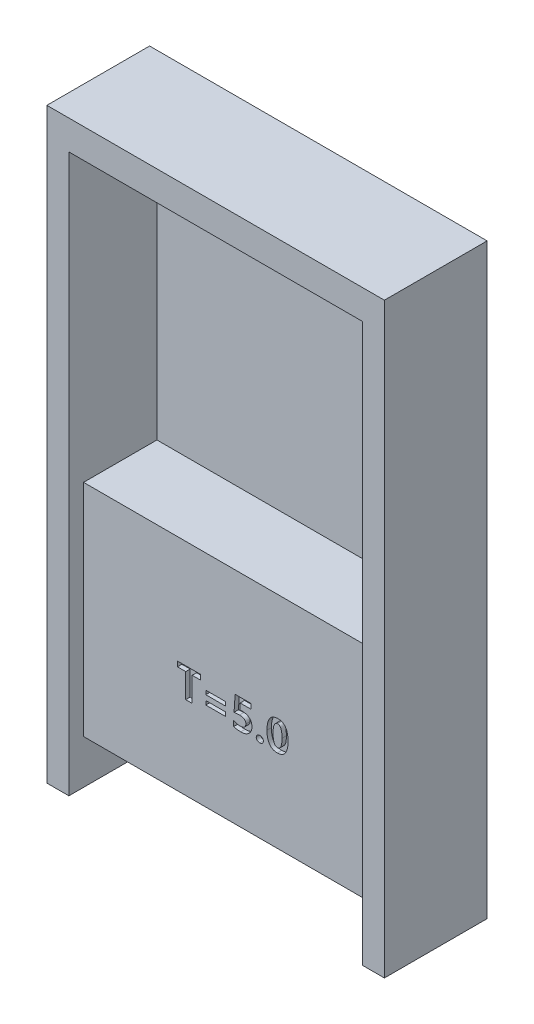
from build123d import *

# Parameters (mm, degrees)
EXTRUDE_1_DEPTH     = 7
SKETCH_2_W          = 20
SKETCH_2_H          = 35
EXTRUDE_2_DEPTH     = 6
SKETCH_3_W          = 20
SKETCH_3_H          = 20
CUT_EXTRUDE_1_DEPTH = 5
SKETCH_4_W          = 14
SKETCH_4_H          = 10
CUT_EXTRUDE_2_DEPTH = 5
SKETCH_5_W          = 1.341463414
SKETCH_5_H          = 0.268292683
CUT_EXTRUDE_3_DEPTH = 0.3


with BuildPart() as part:
    # 草图1 → 凸台-拉伸1 (new body)
    with BuildSketch(Plane.XY):
        Polygon((-10, 0), (-10, -18), (-11.5, -18), (-11.5, 22), (11.5, 22), (11.5, -18), (10, -18), (10, 0), (10, 20), (-10, 20), align=None)
    extrude(amount=EXTRUDE_1_DEPTH)

    # 草图2 → 凸台-拉伸2 (add)
    with BuildSketch(Plane.XY):
        with Locations((0, 2.5)):
            Rectangle(SKETCH_2_W, SKETCH_2_H)
    extrude(amount=EXTRUDE_2_DEPTH)

    # 草图3 → 切除-拉伸1 (cut)
    with BuildSketch(Plane.XY.offset(6)):
        with Locations((0, 10)):
            Rectangle(SKETCH_3_W, SKETCH_3_H)
    extrude(amount=-CUT_EXTRUDE_1_DEPTH, mode=Mode.SUBTRACT)

    # 草图4 → 切除-拉伸2 (cut)
    with BuildSketch(Plane(origin=(0, 0, 0), x_dir=(-1, 0, 0), z_dir=(0, 0, -1))):
        with Locations((0, -7)):
            Rectangle(SKETCH_4_W, SKETCH_4_H)
    extrude(amount=-CUT_EXTRUDE_2_DEPTH, mode=Mode.SUBTRACT)

    # 草图5 → 切除-拉伸3 (cut)
    with BuildSketch(Plane.XY.offset(6)):
        Polygon((-2.038957757, -7.685646489), (-2.599933366, -7.685646489), (-2.599933366, -9.344183074), (-3.038957757, -9.344183074), (-3.038957757, -7.685646489), (-3.599933366, -7.685646489), (-3.599933366, -7.344183074), (-2.038957757, -7.344183074), align=None)
        with Locations((-1.002372391, -8.234426976)):
            Rectangle(SKETCH_5_W, SKETCH_5_H)
        with Locations((-1.002372391, -8.844183075)):
            Rectangle(SKETCH_5_W, SKETCH_5_H)
        with BuildLine():
            Line((0.229334926, -9.295402586), (0.229334926, -8.925356855))
            add(Edge.make_bspline(
                [(0.229334926, -8.925356855), (0.246853092, -8.935526495), (0.281528867, -8.955656466), (0.335668265, -8.981092143), (0.390451653, -9.002970359), (0.446303794, -9.020435919), (0.502817727, -9.034248611), (0.560116273, -9.044076789), (0.61828754, -9.050531549), (0.6574173, -9.051175719), (0.67712456, -9.051500147)],
                knots=[0, 0, 0, 0, 6.0743e-05, 0.000120236, 0.000179257, 0.000237593, 0.00029564, 0.000353657, 0.000411904, 0.000471005, 0.000471005, 0.000471005, 0.000471005], degree=3))
            add(Edge.make_bspline(
                [(0.67712456, -9.051500147), (0.691612565, -9.05114909), (0.71987628, -9.050464235), (0.761189794, -9.046832574), (0.800046633, -9.039946962), (0.836405452, -9.030481393), (0.87041497, -9.018239623), (0.901822524, -9.002955987), (0.93123789, -8.985523282), (0.957451764, -8.964733867), (0.981160271, -8.94195159), (1.001739109, -8.917067078), (1.019613004, -8.89050661), (1.034086771, -8.861850469), (1.045267225, -8.83114514), (1.052533312, -8.798575476), (1.057948019, -8.764330923), (1.058380812, -8.740801848), (1.058603219, -8.728710513)],
                knots=[0, 0, 0, 0, 4.3472e-05, 8.4806e-05, 0.000124279, 0.000161716, 0.000197401, 0.000232514, 0.000266369, 0.00029976, 0.000332641, 0.000364845, 0.000396449, 0.000428491, 0.00046092, 0.000494198, 0.000528475, 0.000564712, 0.000564712, 0.000564712, 0.000564712], degree=3))
            add(Edge.make_bspline(
                [(1.058603219, -8.728710513), (1.058413057, -8.716108246), (1.058044292, -8.691669616), (1.052240625, -8.656248098), (1.044307027, -8.623121831), (1.032132573, -8.592486235), (1.017010056, -8.564189477), (0.998173623, -8.538377152), (0.975600812, -8.515364487), (0.950094772, -8.494265212), (0.920851069, -8.475924131), (0.888246719, -8.460459268), (0.852448984, -8.446994281), (0.813304019, -8.436063532), (0.770594222, -8.427750266), (0.724639123, -8.421835454), (0.675288996, -8.41784191), (0.641309779, -8.417519976), (0.623770902, -8.417353806)],
                knots=[0, 0, 0, 0, 3.7759e-05, 7.3224e-05, 0.000107423, 0.000139765, 0.000171822, 0.000203456, 0.000235259, 0.000268293, 0.00030255, 0.000338515, 0.000376384, 0.000417163, 0.000460287, 0.000506802, 0.000556111, 0.000608715, 0.000608715, 0.000608715, 0.000608715], degree=3))
            add(Edge.make_bspline(
                [(0.623770902, -8.417353806), (0.595944923, -8.417665759), (0.538352972, -8.418311415), (0.448890467, -8.423237055), (0.353320624, -8.430755996), (0.287625259, -8.438003959), (0.25372517, -8.44174405)],
                knots=[0, 0, 0, 0, 8.3474e-05, 0.000172768, 0.000268727, 0.000371038, 0.000371038, 0.000371038, 0.000371038], degree=3))
            Line((0.25372517, -8.44174405), (0.329563585, -7.344183074))
            Line((0.329563585, -7.344183074), (1.400066634, -7.344183074))
            Line((1.400066634, -7.344183074), (1.400066634, -7.685646489))
            Line((1.400066634, -7.685646489), (0.67255139, -7.685646489))
            Line((0.67255139, -7.685646489), (0.643969073, -8.109426977))
            add(Edge.make_bspline(
                [(0.643969073, -8.109426977), (0.678250616, -8.106760797), (0.743959844, -8.10165039), (0.809859057, -8.100723806), (0.841377609, -8.100280635)],
                knots=[0, 0, 0, 0, 0.000103125, 0.000197665, 0.000197665, 0.000197665, 0.000197665], degree=3))
            add(Edge.make_bspline(
                [(0.841377609, -8.100280635), (0.8651485, -8.100842176), (0.911532533, -8.101937907), (0.979275688, -8.109032506), (1.042964579, -8.121710007), (1.103047673, -8.138746832), (1.159161416, -8.161167766), (1.21129347, -8.189000715), (1.260129247, -8.220829217), (1.304257533, -8.258356888), (1.343706516, -8.299940703), (1.379141926, -8.34462581), (1.407696529, -8.393853849), (1.432300709, -8.445912828), (1.450174598, -8.50189027), (1.463753401, -8.561125663), (1.471754401, -8.623944315), (1.472736476, -8.667077236), (1.473237365, -8.689076367)],
                knots=[0, 0, 0, 0, 7.1315e-05, 0.000139157, 0.000204031, 0.000265906, 0.000326271, 0.000384916, 0.000442944, 0.000500816, 0.00055823, 0.000614717, 0.000671449, 0.000728569, 0.000787139, 0.000847324, 0.000910713, 0.000976697, 0.000976697, 0.000976697, 0.000976697], degree=3))
            add(Edge.make_bspline(
                [(1.473237365, -8.689076367), (1.47274996, -8.713505081), (1.471793739, -8.761430849), (1.461377664, -8.831456101), (1.445605891, -8.898178866), (1.423036317, -8.961482565), (1.393693291, -9.021207689), (1.358777314, -9.078093457), (1.316294536, -9.130688886), (1.268403862, -9.179948094), (1.214882082, -9.224279432), (1.156517838, -9.263254952), (1.093290315, -9.295464345), (1.025706638, -9.322368356), (0.953475585, -9.34328416), (0.876552553, -9.358007886), (0.795089901, -9.366830831), (0.739265855, -9.367982958), (0.710661146, -9.368573318)],
                knots=[0, 0, 0, 0, 7.3234e-05, 0.000143675, 0.000211891, 0.000278671, 0.000344802, 0.000411214, 0.000478469, 0.00054719, 0.000617015, 0.000686564, 0.000757299, 0.000829482, 0.000904497, 0.000982527, 0.001064172, 0.001149973, 0.001149973, 0.001149973, 0.001149973], degree=3))
            add(Edge.make_bspline(
                [(0.710661146, -9.368573318), (0.687409838, -9.368362208), (0.641770405, -9.367947824), (0.574651081, -9.364444999), (0.51019341, -9.358795976), (0.448516931, -9.350863401), (0.389629951, -9.340594882), (0.333552129, -9.32799497), (0.280146475, -9.313413695), (0.246037724, -9.301323207), (0.229334926, -9.295402586)],
                knots=[0, 0, 0, 0, 6.975e-05, 0.000136911, 0.00020157, 0.000263824, 0.000323408, 0.000380824, 0.000436209, 0.000489357, 0.000489357, 0.000489357, 0.000489357], degree=3))
        make_face()
        with BuildLine():
            add(Edge.make_bspline(
                [(1.765920292, -9.148298928), (1.766728688, -9.13293706), (1.768306553, -9.10295307), (1.782811043, -9.060401528), (1.805672247, -9.022074277), (1.837676301, -8.989577343), (1.875610321, -8.963244909), (1.91772659, -8.943269281), (1.963730332, -8.93166491), (1.995531011, -8.93026298), (2.011728219, -8.929548928)],
                knots=[0, 0, 0, 0, 4.596e-05, 8.9706e-05, 0.0001333, 0.000178849, 0.000225368, 0.000271229, 0.000317999, 0.000366548, 0.000366548, 0.000366548, 0.000366548], degree=3))
            add(Edge.make_bspline(
                [(2.011728219, -8.929548928), (2.028065988, -8.930204709), (2.05992891, -8.931483653), (2.105735531, -8.943744006), (2.147528564, -8.963762738), (2.18423842, -8.991316277), (2.215381989, -9.023891566), (2.237566329, -9.062037881), (2.251651901, -9.103881831), (2.253026177, -9.133323908), (2.25372517, -9.148298928)],
                knots=[0, 0, 0, 0, 4.8929e-05, 9.5425e-05, 0.000141105, 0.000187143, 0.000232444, 0.00027532, 0.000318586, 0.000363371, 0.000363371, 0.000363371, 0.000363371], degree=3))
            add(Edge.make_bspline(
                [(2.25372517, -9.148298928), (2.253059897, -9.164038906), (2.251767619, -9.194613446), (2.237626519, -9.237827101), (2.215707139, -9.276743138), (2.184233619, -9.309179905), (2.147084973, -9.336108296), (2.104121523, -9.354752487), (2.056955565, -9.366632061), (2.023871778, -9.367911895), (2.006773951, -9.368573318)],
                knots=[0, 0, 0, 0, 4.7062e-05, 9.1417e-05, 0.000134952, 0.000179975, 0.000225872, 0.000271763, 0.000319642, 0.000370851, 0.000370851, 0.000370851, 0.000370851], degree=3))
            add(Edge.make_bspline(
                [(2.006773951, -9.368573318), (1.990685107, -9.367928817), (1.959312571, -9.366672068), (1.914249958, -9.354238924), (1.872689627, -9.334587328), (1.835651356, -9.307320667), (1.804757726, -9.274061435), (1.781858097, -9.235889571), (1.768574281, -9.193232366), (1.766818533, -9.163506622), (1.765920292, -9.148298928)],
                knots=[0, 0, 0, 0, 4.8169e-05, 9.3928e-05, 0.0001391, 0.000185444, 0.000231025, 0.000274423, 0.000317937, 0.000363517, 0.000363517, 0.000363517, 0.000363517], degree=3))
        make_face()
        with BuildLine():
            add(Edge.make_bspline(
                [(2.497627609, -8.376195269), (2.498230233, -8.33464218), (2.499401877, -8.253853166), (2.507935403, -8.136474627), (2.523257169, -8.026666137), (2.543957517, -7.924494932), (2.570431815, -7.82963793), (2.603539961, -7.742666222), (2.642506018, -7.663044715), (2.687420852, -7.591114942), (2.738230473, -7.527107963), (2.794453931, -7.471292359), (2.856427318, -7.424387451), (2.923674341, -7.385964838), (2.996325018, -7.356118715), (3.074234537, -7.334776161), (3.157523848, -7.32205823), (3.214807974, -7.320560992), (3.244197731, -7.31979283)],
                knots=[0, 0, 0, 0, 0.000124656, 0.000242361, 0.000352793, 0.000457056, 0.000554894, 0.000647895, 0.00073584, 0.00082043, 0.00090179, 0.000980479, 0.001057462, 0.001134275, 0.001212195, 0.001292447, 0.001376096, 0.001464229, 0.001464229, 0.001464229, 0.001464229], degree=3))
            add(Edge.make_bspline(
                [(3.244197731, -7.31979283), (3.272188336, -7.320454731), (3.326656093, -7.321742742), (3.40556172, -7.333729971), (3.479155402, -7.353532371), (3.547305111, -7.381394564), (3.610203574, -7.417109594), (3.66731398, -7.461027231), (3.719369716, -7.512602014), (3.765440046, -7.572474148), (3.806041453, -7.640202958), (3.840792411, -7.715765572), (3.871231096, -7.79870889), (3.89465707, -7.889985846), (3.913746585, -7.988857083), (3.927247967, -8.095650511), (3.93522796, -8.210294457), (3.936167079, -8.289291677), (3.936651999, -8.330082464)],
                knots=[0, 0, 0, 0, 8.3928e-05, 0.000163318, 0.000238757, 0.000312076, 0.000383594, 0.000455091, 0.000527581, 0.00060282, 0.000681118, 0.000763978, 0.000851986, 0.000945811, 0.001046338, 0.001153923, 0.001268532, 0.001390894, 0.001390894, 0.001390894, 0.001390894], degree=3))
            add(Edge.make_bspline(
                [(3.936651999, -8.330082464), (3.936078467, -8.370369234), (3.934964346, -8.448628653), (3.926028121, -8.562499037), (3.911921795, -8.669355116), (3.891418027, -8.769247732), (3.86484227, -8.862031598), (3.832528954, -8.94779122), (3.794366517, -9.026531177), (3.750285056, -9.097881664), (3.700560757, -9.161660234), (3.645584346, -9.217253621), (3.585208639, -9.264531097), (3.518975101, -9.302204726), (3.448027235, -9.332214433), (3.37176209, -9.353641392), (3.290226755, -9.366282859), (3.234080484, -9.367797573), (3.20532578, -9.368573318)],
                knots=[0, 0, 0, 0, 0.000120846, 0.000234751, 0.000342437, 0.00044401, 0.000540382, 0.000631688, 0.000718612, 0.000802475, 0.000882828, 0.000960707, 0.001036481, 0.001112112, 0.001188625, 0.001267042, 0.001349185, 0.001435415, 0.001435415, 0.001435415, 0.001435415], degree=3))
            add(Edge.make_bspline(
                [(3.20532578, -9.368573318), (3.176697592, -9.367928702), (3.121086839, -9.366676523), (3.040492389, -9.354482679), (2.96536629, -9.335312264), (2.895724029, -9.308057618), (2.831433459, -9.273186689), (2.772769474, -9.230324846), (2.720045831, -9.179150151), (2.672642567, -9.12059726), (2.631000854, -9.054116075), (2.595194597, -8.979897861), (2.564766207, -8.898106694), (2.540293114, -8.808510441), (2.520805095, -8.711369853), (2.507553962, -8.606420119), (2.498913399, -8.493845677), (2.49806512, -8.416227709), (2.497627609, -8.376195269)],
                knots=[0, 0, 0, 0, 8.5832e-05, 0.000166729, 0.000243912, 0.000318008, 0.000390486, 0.000462747, 0.000535249, 0.000610302, 0.000688227, 0.000770039, 0.000857106, 0.000949659, 0.00104839, 0.001154086, 0.001266822, 0.001386897, 0.001386897, 0.001386897, 0.001386897], degree=3))
        make_face()
        with BuildLine():
            add(Edge.make_bspline(
                [(2.912261755, -8.365905635), (2.912417692, -8.39360479), (2.912719713, -8.447252922), (2.916828949, -8.524889783), (2.922221966, -8.597260998), (2.930469688, -8.664315304), (2.941590032, -8.72595059), (2.954360971, -8.782418994), (2.969672169, -8.833521131), (2.988282903, -8.879062592), (3.008004884, -8.919818674), (3.031082191, -8.954799948), (3.056430751, -8.984647806), (3.084237425, -9.009331136), (3.114831663, -9.028304927), (3.147659342, -9.041768667), (3.182938181, -9.050088808), (3.207311765, -9.051021817), (3.219807487, -9.051500147)],
                knots=[0, 0, 0, 0, 8.3087e-05, 0.000160924, 0.000233178, 0.000300773, 0.000363493, 0.000420993, 0.000474397, 0.000523298, 0.000568462, 0.000610002, 0.000648651, 0.000685649, 0.000721077, 0.000756109, 0.0007917, 0.000829143, 0.000829143, 0.000829143, 0.000829143], degree=3))
            add(Edge.make_bspline(
                [(3.219807487, -9.051500147), (3.232054803, -9.051044613), (3.256090741, -9.050150606), (3.290746144, -9.041417208), (3.32310727, -9.027469832), (3.352966, -9.007822508), (3.380401064, -8.982536814), (3.405129028, -8.951677157), (3.427585898, -8.915533097), (3.447871619, -8.874087397), (3.465211652, -8.826879658), (3.480140971, -8.774183385), (3.493766246, -8.716290847), (3.503540338, -8.652654854), (3.512036095, -8.58366258), (3.518050044, -8.509034943), (3.521389094, -8.428945287), (3.521803864, -8.37378486), (3.522017853, -8.345326367)],
                knots=[0, 0, 0, 0, 3.6682e-05, 7.1991e-05, 0.000106469, 0.000141985, 0.00017867, 0.000217952, 0.000260247, 0.000306095, 0.000356141, 0.000410897, 0.000470339, 0.000534433, 0.000603919, 0.000678863, 0.000758967, 0.00084434, 0.00084434, 0.00084434, 0.00084434], degree=3))
            add(Edge.make_bspline(
                [(3.522017853, -8.345326367), (3.521812706, -8.316740336), (3.52141502, -8.261324969), (3.517960563, -8.180998139), (3.512387699, -8.106242247), (3.504397954, -8.037079025), (3.494394144, -7.97327604), (3.481339759, -7.915074789), (3.466762486, -7.862246785), (3.44958859, -7.815078633), (3.430305151, -7.773171344), (3.408384616, -7.736902467), (3.383975207, -7.706238424), (3.357713411, -7.680546194), (3.32844861, -7.660936371), (3.296870538, -7.646946085), (3.263083127, -7.638248179), (3.239676413, -7.637330973), (3.227810536, -7.636866001)],
                knots=[0, 0, 0, 0, 8.5755e-05, 0.000166239, 0.000241153, 0.000310594, 0.000375064, 0.000434794, 0.000489445, 0.000539359, 0.000585221, 0.000627639, 0.000666147, 0.000702535, 0.000737416, 0.000771196, 0.000805765, 0.000841307, 0.000841307, 0.000841307, 0.000841307], degree=3))
            add(Edge.make_bspline(
                [(3.227810536, -7.636866001), (3.215048074, -7.63728457), (3.189965152, -7.638107212), (3.153861293, -7.647395754), (3.119906889, -7.661471852), (3.088936845, -7.682219799), (3.060000918, -7.707953809), (3.033999343, -7.739686369), (3.010795822, -7.777108501), (2.989918812, -7.820071396), (2.971285676, -7.868633588), (2.955410165, -7.92295479), (2.942276735, -7.982972938), (2.931339585, -8.048613852), (2.922545915, -8.119933845), (2.916757897, -8.196876374), (2.912735513, -8.279480713), (2.91242334, -8.336428731), (2.912261755, -8.365905635)],
                knots=[0, 0, 0, 0, 3.8203e-05, 7.5083e-05, 0.000111112, 0.000148002, 0.000186328, 0.000226926, 0.000270594, 0.000318146, 0.000370023, 0.000426456, 0.000487757, 0.000554231, 0.000626033, 0.000703256, 0.000785661, 0.000874083, 0.000874083, 0.000874083, 0.000874083], degree=3))
        make_face(mode=Mode.SUBTRACT)
    extrude(amount=-CUT_EXTRUDE_3_DEPTH, mode=Mode.SUBTRACT)


solid = part.part
